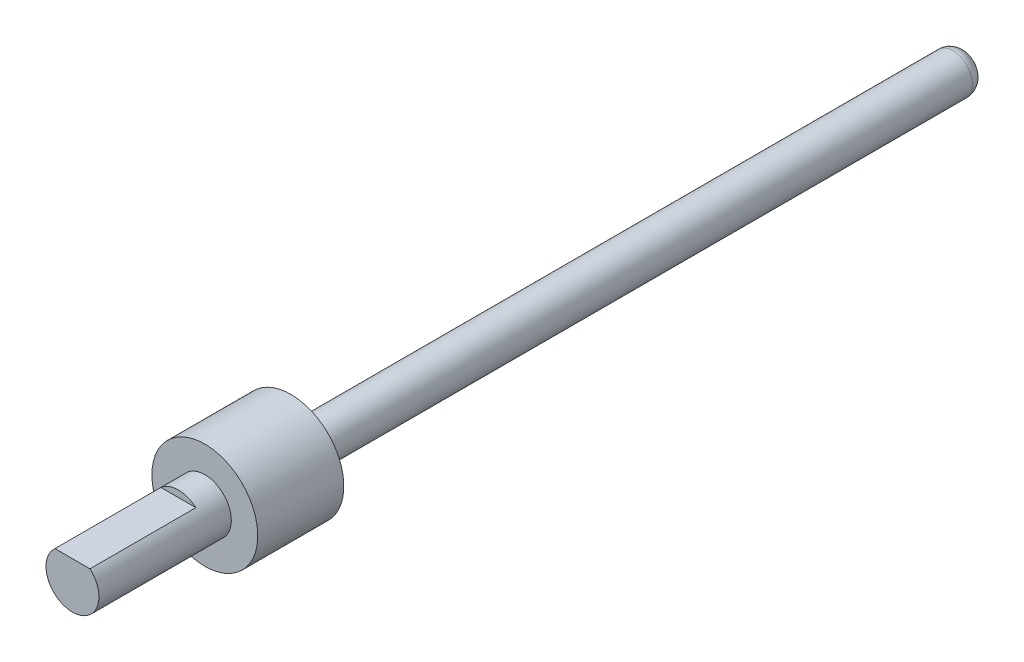
from build123d import *

# Parameters (mm, degrees)
SKETCH1_R       = 2
EXTRUDE1_DEPTH  = 10
EXTRUDE2_DEPTH  = 8
SKETCH3_R       = 4
EXTRUDE3_DEPTH  = 6.5
SKETCH19_R      = 1.5
EXTRUDE13_DEPTH = 51
FILLET11_R      = 1


with BuildPart() as part:
    # Sketch1 → Extrude1 (new body)
    with BuildSketch(Plane.XY):
        Circle(SKETCH1_R)
    extrude(amount=-EXTRUDE1_DEPTH)

    # Sketch2 → Extrude2 (cut)
    with BuildSketch(Plane.XY):
        with BuildLine():
            Line((-1.322875656, 1.5), (1.322875656, 1.5))
            ThreePointArc((1.322875656, 1.5), (0, 2), (-1.322875656, 1.5))
        make_face()
    extrude(amount=-EXTRUDE2_DEPTH, mode=Mode.SUBTRACT)

    # Sketch3 → Extrude3 (add)
    with BuildSketch(Plane(origin=(0, 0, -10), x_dir=(-1, 0, 0), z_dir=(0, 0, -1))):
        Circle(SKETCH3_R)
    extrude(amount=EXTRUDE3_DEPTH)

    # Sketch19 → Extrude13 (add)
    with BuildSketch(Plane(origin=(0, 0, -16.5), x_dir=(-1, 0, 0), z_dir=(0, 0, -1))):
        Circle(SKETCH19_R)
    extrude(amount=EXTRUDE13_DEPTH)

    # Fillet11
    fillet11_edges = [part.edges().sort_by_distance(p)[0] for p in [
        (1.5, 0, -67.5),
    ]]
    fillet(fillet11_edges, radius=FILLET11_R)


solid = part.part
